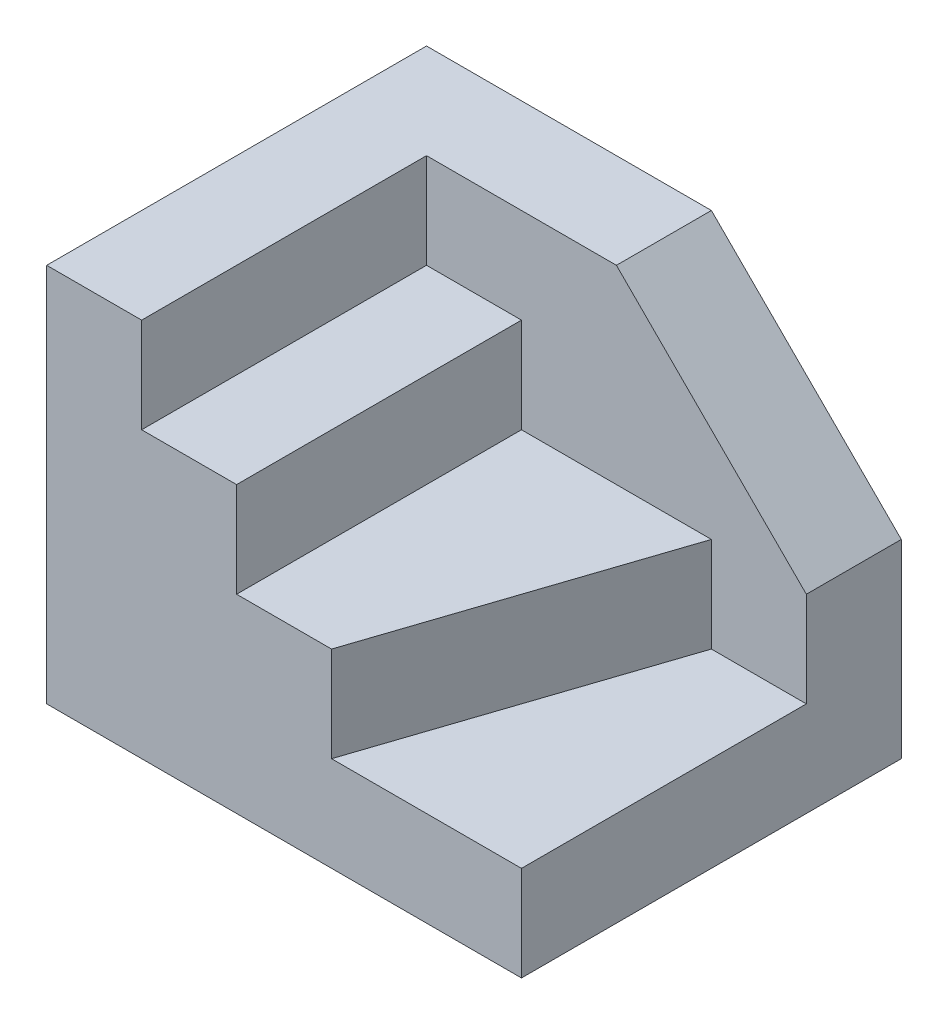
from build123d import *

# Parameters (mm, degrees)
SKETCH_1_W          = 50
SKETCH_1_H          = 40
EXTRUDE_1_DEPTH     = 40
CUT_EXTRUDE_1_DEPTH = 30
EXTRUDE_2_DEPTH     = 10
CUT_EXTRUDE_2_DEPTH = 11


with BuildPart() as part:
    # 草圖1 → 填料-伸長1 (new body)
    with BuildSketch(Plane(origin=(0, 0, 0), x_dir=(1, 0, 0), z_dir=(0, 1, 0))):
        Rectangle(SKETCH_1_W, SKETCH_1_H)
    extrude(amount=EXTRUDE_1_DEPTH)

    # 草圖2 → 除料-伸長1 (cut)
    with BuildSketch(Plane.XY.offset(20)):
        Polygon((-15, 40), (-15, 30), (-5, 30), (-5, 20), (5, 20), (5, 10), (25, 10), (25, 40), align=None)
    extrude(amount=-CUT_EXTRUDE_1_DEPTH, mode=Mode.SUBTRACT)

    # 草圖3 → 填料-伸長2 (add)
    with BuildSketch(Plane(origin=(0, 10, 0), x_dir=(1, 0, 0), z_dir=(0, 1, 0))):
        Polygon((5, -20), (15, 10), (5, 10), align=None)
    extrude(amount=EXTRUDE_2_DEPTH)

    # 草圖4 → 除料-伸長2 (cut, through all)
    with BuildSketch(Plane.XY.offset(-10)):
        Polygon((5, 40), (25, 20), (25, 40), align=None)
    extrude(amount=-CUT_EXTRUDE_2_DEPTH, mode=Mode.SUBTRACT)


solid = part.part
